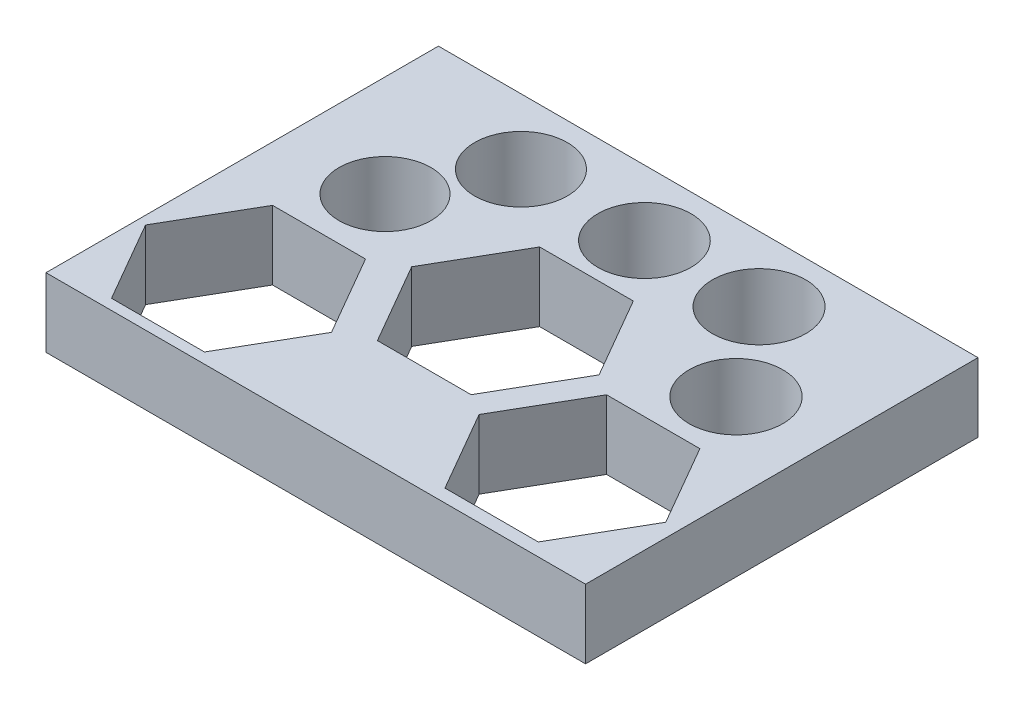
from build123d import *

# Parameters (mm, degrees)
SKETCH1_W           = 23.454698607
SKETCH1_H           = 17.05901257
SKETCH1_R           = 2
SKETCH1_R_2         = 2.015
SKETCH1_R_3         = 2.03
SKETCH1_R_4         = 2.025
SKETCH1_R_5         = 2.035
BOSS_EXTRUDE1_DEPTH = 3


with BuildPart() as part:
    # Sketch1 → Boss-Extrude1 (new body)
    with BuildSketch(Plane(origin=(0, 0, 0), x_dir=(1, 0, 0), z_dir=(0, 1, 0))):
        with Locations((11.727349304, 8.529506285)):
            Rectangle(SKETCH1_W, SKETCH1_H)
        with Locations((4.409007026, 10.327471093)):
            Circle(SKETCH1_R, mode=Mode.SUBTRACT)
        with Locations((6.429732026, 14.216806169)):
            Circle(SKETCH1_R_2, mode=Mode.SUBTRACT)
        with Locations((16.77995554, 14.216806169)):
            Circle(SKETCH1_R_3, mode=Mode.SUBTRACT)
        with Locations((11.796158167, 14.216806169)):
            Circle(SKETCH1_R_4, mode=Mode.SUBTRACT)
        with Locations((19.665090072, 10.327471093)):
            Circle(SKETCH1_R_5, mode=Mode.SUBTRACT)
        Polygon((6.429732026, 7.459514329), (2.388282026, 7.459514329), (0.367557026, 3.959515961), (2.388282026, 0.459517593), (6.429732026, 0.459517593), (8.450457026, 3.959515961), align=None, mode=Mode.SUBTRACT)
        Polygon((13.831883167, 11.698479726), (9.760433167, 11.698479726), (7.724708167, 8.172500596), (9.760433167, 4.646521466), (13.831883167, 4.646521466), (15.867608167, 8.172500596), align=None, mode=Mode.SUBTRACT)
        Polygon((20.83640554, 7.587928947), (16.77995554, 7.587928947), (14.75173054, 4.074940198), (16.77995554, 0.561951448), (20.83640554, 0.561951448), (22.86463054, 4.074940198), align=None, mode=Mode.SUBTRACT)
    extrude(amount=BOSS_EXTRUDE1_DEPTH)


solid = part.part
